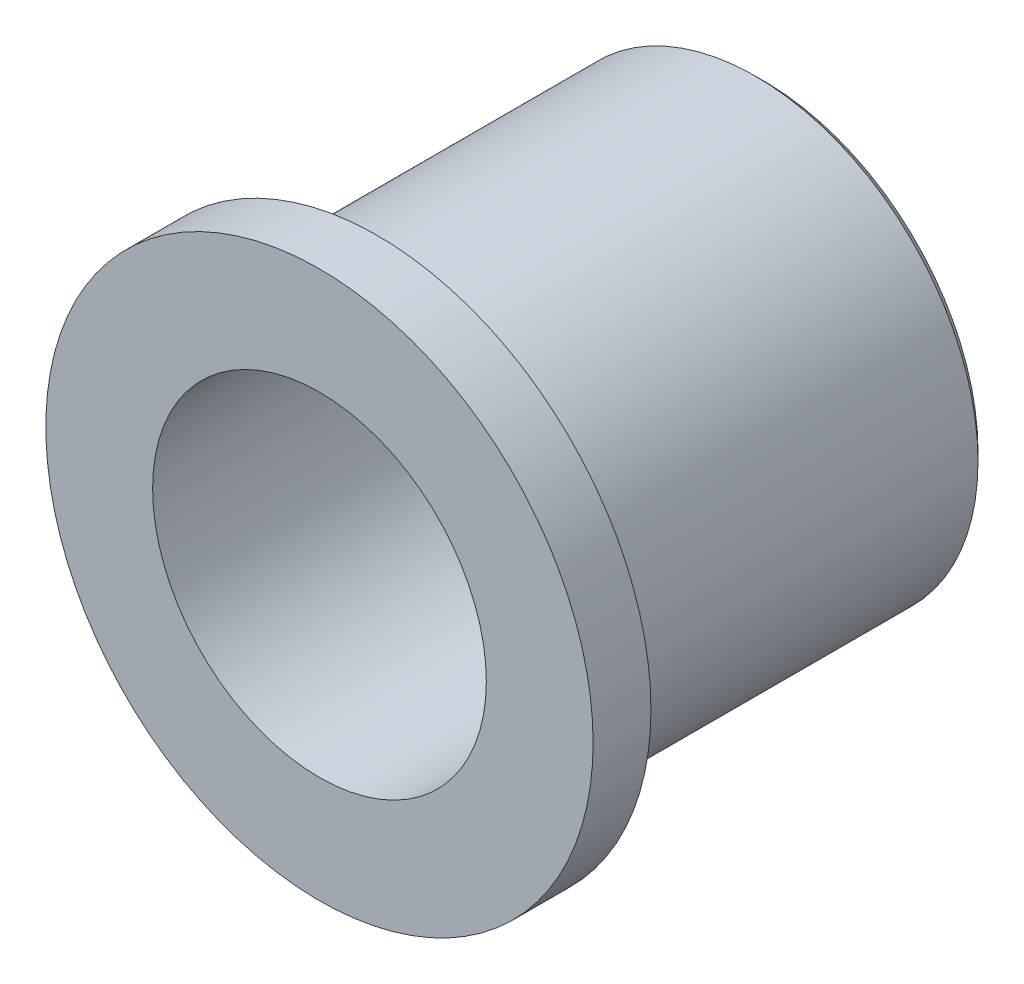
from build123d import *

# Parameters (mm, degrees)
F_1_4_0_75_DIAMETER_HOLE1_D = 19.05
CHAMFER1_SIZE               = 0.508


with BuildPart() as part:
    # Sketch1 → Revolve1 (revolve)
    with BuildSketch(Plane(origin=(0, 0, 0), x_dir=(0, 0, -1), z_dir=(1, 0, 0))):
        Polygon((0, 0), (-25.4, 0), (-25.4, 15.621), (-22.098, 15.621), (-22.098, 12.7), (0, 12.7), align=None)
    revolve(axis=Axis((0, 0, 0), (0, 0, -1)))

    # 1_4 _0.75_ Diameter Hole1 (through all)
    with Locations(Plane.XY.offset(25.4)):
        with Locations((0, 0)):
            Hole(F_1_4_0_75_DIAMETER_HOLE1_D / 2)

    # Chamfer1
    chamfer1_edges = [part.edges().sort_by_distance(p)[0] for p in [
        (0, -12.7, 0),
    ]]
    chamfer(chamfer1_edges, length=CHAMFER1_SIZE)


solid = part.part
